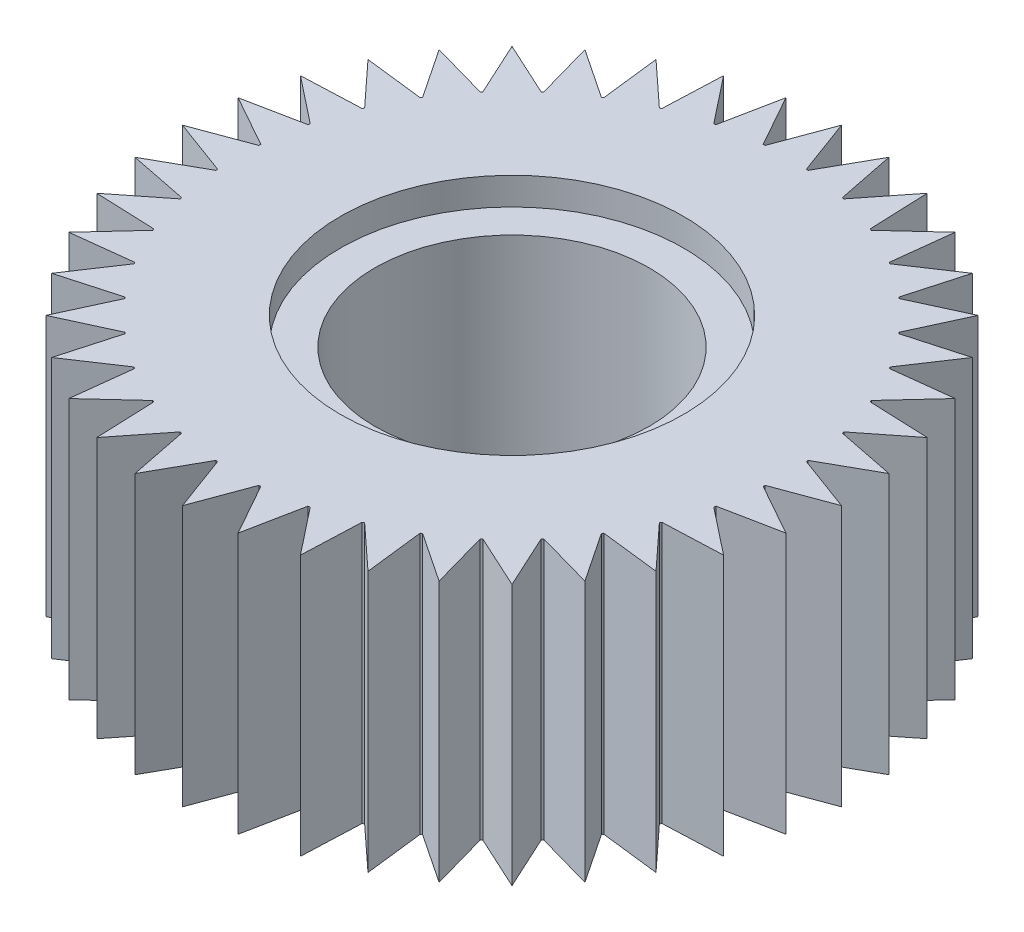
from build123d import *

# Parameters (mm, degrees)
CROQUIS1_R              = 10
CROQUIS1_R_2            = 3
SALIENTE_EXTRUIR1_DEPTH = 19
CROQUIS2_R              = 10
SALIENTE_EXTRUIR2_DEPTH = 19
CROQUIS3_R              = 10
CORTAR_EXTRUIR1_DEPTH   = 20
CROQUIS4_R              = 12.5
CORTAR_EXTRUIR2_DEPTH   = 2
CROQUIS5_R              = 12.5
CORTAR_EXTRUIR3_DEPTH   = 2


with BuildPart() as part:
    # Croquis1 → Saliente-Extruir1 (new body)
    with BuildSketch(Plane(origin=(0, 0, 0), x_dir=(1, 0, 0), z_dir=(0, 1, 0))):
        Circle(CROQUIS1_R)
        Circle(CROQUIS1_R_2, mode=Mode.SUBTRACT)
    extrude(amount=SALIENTE_EXTRUIR1_DEPTH)

    # Croquis2 → Saliente-Extruir2 (add)
    with BuildSketch(Plane(origin=(0, 19, 0), x_dir=(1, 0, 0), z_dir=(0, 1, 0))):
        with BuildLine():
            Line((-1.5, -19.943670675), (0, -24))
            Line((0, -24), (1.5, -19.943670675))
            ThreePointArc((1.5, -19.943670675), (1.569181915, -19.938346675), (1.638344942, -19.932782692))
            Line((1.638344942, -19.932782692), (3.754427161, -23.704520174))
            Line((3.754427161, -23.704520174), (4.601409964, -19.463479297))
            ThreePointArc((4.601409964, -19.463479297), (4.668907277, -19.447398408), (4.736348394, -19.431083446))
            Line((4.736348394, -19.431083446), (7.416407865, -22.825356391))
            Line((7.416407865, -22.825356391), (7.589517943, -18.504032463))
            ThreePointArc((7.589517943, -18.504032463), (7.653668647, -18.47759065), (7.71772723, -18.450926437))
            Line((7.71772723, -18.450926437), (10.895771994, -21.384156581))
            Line((10.895771994, -21.384156581), (10.390746803, -17.088954938))
            ThreePointArc((10.390746803, -17.088954938), (10.449971294, -17.052803287), (10.509070008, -17.016446385))
            Line((10.509070008, -17.016446385), (14.106846055, -19.416407865))
            Line((14.106846055, -19.416407865), (12.936120991, -15.253090628))
            ThreePointArc((12.936120991, -15.253090628), (12.988960967, -15.208119312), (13.041644604, -15.162964948))
            Line((13.041644604, -15.162964948), (16.970562748, -16.970562748))
            Line((16.970562748, -16.970562748), (15.162964948, -13.041644604))
            ThreePointArc((15.162964948, -13.041644604), (15.208119312, -12.988960967), (15.253090628, -12.936120991))
            Line((15.253090628, -12.936120991), (19.416407865, -14.106846055))
            Line((19.416407865, -14.106846055), (17.016446385, -10.509070008))
            ThreePointArc((17.016446385, -10.509070008), (17.052803287, -10.449971294), (17.088954938, -10.390746803))
            Line((17.088954938, -10.390746803), (21.384156581, -10.895771994))
            Line((21.384156581, -10.895771994), (18.450926437, -7.71772723))
            ThreePointArc((18.450926437, -7.71772723), (18.47759065, -7.653668647), (18.504032463, -7.589517943))
            Line((18.504032463, -7.589517943), (22.825356391, -7.416407865))
            Line((22.825356391, -7.416407865), (19.431083446, -4.736348394))
            ThreePointArc((19.431083446, -4.736348394), (19.447398408, -4.668907277), (19.463479297, -4.601409964))
            Line((19.463479297, -4.601409964), (23.704520174, -3.754427161))
            Line((23.704520174, -3.754427161), (19.932782692, -1.638344942))
            ThreePointArc((19.932782692, -1.638344942), (19.938346675, -1.569181915), (19.943670675, -1.5))
            Line((19.943670675, -1.5), (24, 0))
            Line((24, 0), (19.943670675, 1.5))
            ThreePointArc((19.943670675, 1.5), (19.938346675, 1.569181915), (19.932782692, 1.638344942))
            Line((19.932782692, 1.638344942), (23.704520174, 3.754427161))
            Line((23.704520174, 3.754427161), (19.463479297, 4.601409964))
            ThreePointArc((19.463479297, 4.601409964), (19.447398408, 4.668907277), (19.431083446, 4.736348394))
            Line((19.431083446, 4.736348394), (22.825356391, 7.416407865))
            Line((22.825356391, 7.416407865), (18.504032463, 7.589517943))
            ThreePointArc((18.504032463, 7.589517943), (18.47759065, 7.653668647), (18.450926437, 7.71772723))
            Line((18.450926437, 7.71772723), (21.384156581, 10.895771994))
            Line((21.384156581, 10.895771994), (17.088954938, 10.390746803))
            ThreePointArc((17.088954938, 10.390746803), (17.052803287, 10.449971294), (17.016446385, 10.509070008))
            Line((17.016446385, 10.509070008), (19.416407865, 14.106846055))
            Line((19.416407865, 14.106846055), (15.253090628, 12.936120991))
            ThreePointArc((15.253090628, 12.936120991), (15.208119312, 12.988960967), (15.162964948, 13.041644604))
            Line((15.162964948, 13.041644604), (16.970562748, 16.970562748))
            Line((16.970562748, 16.970562748), (13.041644604, 15.162964948))
            ThreePointArc((13.041644604, 15.162964948), (12.988960967, 15.208119312), (12.936120991, 15.253090628))
            Line((12.936120991, 15.253090628), (14.106846055, 19.416407865))
            Line((14.106846055, 19.416407865), (10.509070008, 17.016446385))
            ThreePointArc((10.509070008, 17.016446385), (10.449971294, 17.052803287), (10.390746803, 17.088954938))
            Line((10.390746803, 17.088954938), (10.895771994, 21.384156581))
            Line((10.895771994, 21.384156581), (7.71772723, 18.450926437))
            ThreePointArc((7.71772723, 18.450926437), (7.653668647, 18.47759065), (7.589517943, 18.504032463))
            Line((7.589517943, 18.504032463), (7.416407865, 22.825356391))
            Line((7.416407865, 22.825356391), (4.736348394, 19.431083446))
            ThreePointArc((4.736348394, 19.431083446), (4.668907277, 19.447398408), (4.601409964, 19.463479297))
            Line((4.601409964, 19.463479297), (3.754427161, 23.704520174))
            Line((3.754427161, 23.704520174), (1.638344942, 19.932782692))
            ThreePointArc((1.638344942, 19.932782692), (1.569181915, 19.938346675), (1.5, 19.943670675))
            Line((1.5, 19.943670675), (0, 24))
            Line((0, 24), (-1.5, 19.943670675))
            ThreePointArc((-1.5, 19.943670675), (-1.569181915, 19.938346675), (-1.638344942, 19.932782692))
            Line((-1.638344942, 19.932782692), (-3.754427161, 23.704520174))
            Line((-3.754427161, 23.704520174), (-4.601409964, 19.463479297))
            ThreePointArc((-4.601409964, 19.463479297), (-4.668907277, 19.447398408), (-4.736348394, 19.431083446))
            Line((-4.736348394, 19.431083446), (-7.416407865, 22.825356391))
            Line((-7.416407865, 22.825356391), (-7.589517943, 18.504032463))
            ThreePointArc((-7.589517943, 18.504032463), (-7.653668647, 18.47759065), (-7.71772723, 18.450926437))
            Line((-7.71772723, 18.450926437), (-10.895771994, 21.384156581))
            Line((-10.895771994, 21.384156581), (-10.390746803, 17.088954938))
            ThreePointArc((-10.390746803, 17.088954938), (-10.449971294, 17.052803287), (-10.509070008, 17.016446385))
            Line((-10.509070008, 17.016446385), (-14.106846055, 19.416407865))
            Line((-14.106846055, 19.416407865), (-12.936120991, 15.253090628))
            ThreePointArc((-12.936120991, 15.253090628), (-12.988960967, 15.208119312), (-13.041644604, 15.162964948))
            Line((-13.041644604, 15.162964948), (-16.970562748, 16.970562748))
            Line((-16.970562748, 16.970562748), (-15.162964948, 13.041644604))
            ThreePointArc((-15.162964948, 13.041644604), (-15.208119312, 12.988960967), (-15.253090628, 12.936120991))
            Line((-15.253090628, 12.936120991), (-19.416407865, 14.106846055))
            Line((-19.416407865, 14.106846055), (-17.016446385, 10.509070008))
            ThreePointArc((-17.016446385, 10.509070008), (-17.052803287, 10.449971294), (-17.088954938, 10.390746803))
            Line((-17.088954938, 10.390746803), (-21.384156581, 10.895771994))
            Line((-21.384156581, 10.895771994), (-18.450926437, 7.71772723))
            ThreePointArc((-18.450926437, 7.71772723), (-18.47759065, 7.653668647), (-18.504032463, 7.589517943))
            Line((-18.504032463, 7.589517943), (-22.825356391, 7.416407865))
            Line((-22.825356391, 7.416407865), (-19.431083446, 4.736348394))
            ThreePointArc((-19.431083446, 4.736348394), (-19.447398408, 4.668907277), (-19.463479297, 4.601409964))
            Line((-19.463479297, 4.601409964), (-23.704520174, 3.754427161))
            Line((-23.704520174, 3.754427161), (-19.932782692, 1.638344942))
            ThreePointArc((-19.932782692, 1.638344942), (-19.938346675, 1.569181915), (-19.943670675, 1.5))
            Line((-19.943670675, 1.5), (-24, 0))
            Line((-24, 0), (-19.943670675, -1.5))
            ThreePointArc((-19.943670675, -1.5), (-19.938346675, -1.569181915), (-19.932782692, -1.638344942))
            Line((-19.932782692, -1.638344942), (-23.704520174, -3.754427161))
            Line((-23.704520174, -3.754427161), (-19.463479297, -4.601409964))
            ThreePointArc((-19.463479297, -4.601409964), (-19.447398408, -4.668907277), (-19.431083446, -4.736348394))
            Line((-19.431083446, -4.736348394), (-22.825356391, -7.416407865))
            Line((-22.825356391, -7.416407865), (-18.504032463, -7.589517943))
            ThreePointArc((-18.504032463, -7.589517943), (-18.47759065, -7.653668647), (-18.450926437, -7.71772723))
            Line((-18.450926437, -7.71772723), (-21.384156581, -10.895771994))
            Line((-21.384156581, -10.895771994), (-17.088954938, -10.390746803))
            ThreePointArc((-17.088954938, -10.390746803), (-17.052803287, -10.449971294), (-17.016446385, -10.509070008))
            Line((-17.016446385, -10.509070008), (-19.416407865, -14.106846055))
            Line((-19.416407865, -14.106846055), (-15.253090628, -12.936120991))
            ThreePointArc((-15.253090628, -12.936120991), (-15.208119312, -12.988960967), (-15.162964948, -13.041644604))
            Line((-15.162964948, -13.041644604), (-16.970562748, -16.970562748))
            Line((-16.970562748, -16.970562748), (-13.041644604, -15.162964948))
            ThreePointArc((-13.041644604, -15.162964948), (-12.988960967, -15.208119312), (-12.936120991, -15.253090628))
            Line((-12.936120991, -15.253090628), (-14.106846055, -19.416407865))
            Line((-14.106846055, -19.416407865), (-10.509070008, -17.016446385))
            ThreePointArc((-10.509070008, -17.016446385), (-10.449971294, -17.052803287), (-10.390746803, -17.088954938))
            Line((-10.390746803, -17.088954938), (-10.895771994, -21.384156581))
            Line((-10.895771994, -21.384156581), (-7.71772723, -18.450926437))
            ThreePointArc((-7.71772723, -18.450926437), (-7.653668647, -18.47759065), (-7.589517943, -18.504032463))
            Line((-7.589517943, -18.504032463), (-7.416407865, -22.825356391))
            Line((-7.416407865, -22.825356391), (-4.736348394, -19.431083446))
            ThreePointArc((-4.736348394, -19.431083446), (-4.668907277, -19.447398408), (-4.601409964, -19.463479297))
            Line((-4.601409964, -19.463479297), (-3.754427161, -23.704520174))
            Line((-3.754427161, -23.704520174), (-1.638344942, -19.932782692))
            ThreePointArc((-1.638344942, -19.932782692), (-1.569181915, -19.938346675), (-1.5, -19.943670675))
        make_face()
        Circle(CROQUIS2_R, mode=Mode.SUBTRACT)
    extrude(amount=-SALIENTE_EXTRUIR2_DEPTH)

    # Croquis3 → Cortar-Extruir1 (cut, through all)
    with BuildSketch(Plane.XZ):
        Circle(CROQUIS3_R)
    extrude(amount=-CORTAR_EXTRUIR1_DEPTH, mode=Mode.SUBTRACT)

    # Croquis4 → Cortar-Extruir2 (cut)
    with BuildSketch(Plane(origin=(0, 19, 0), x_dir=(1, 0, 0), z_dir=(0, 1, 0))):
        Circle(CROQUIS4_R)
    extrude(amount=-CORTAR_EXTRUIR2_DEPTH, mode=Mode.SUBTRACT)

    # Croquis5 → Cortar-Extruir3 (cut)
    with BuildSketch(Plane.XZ):
        Circle(CROQUIS5_R)
    extrude(amount=-CORTAR_EXTRUIR3_DEPTH, mode=Mode.SUBTRACT)


solid = part.part
